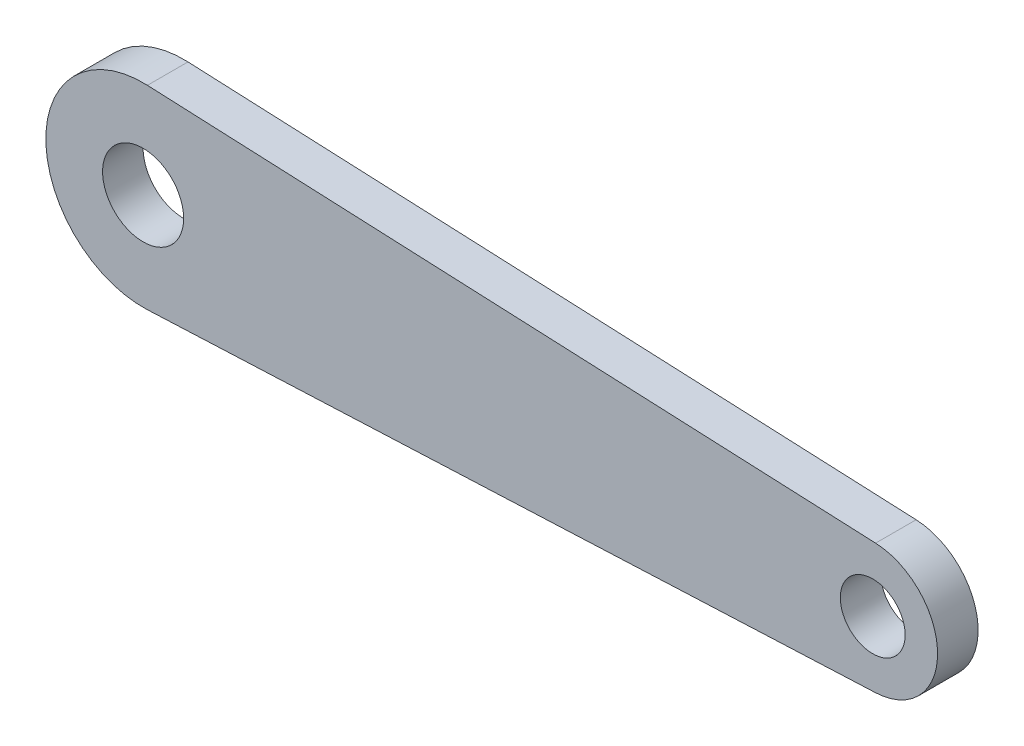
from build123d import *

# Parameters (mm, degrees)
SKETCH1_R           = 3.175
SKETCH1_R_2         = 2.54
BOSS_EXTRUDE1_DEPTH = 3.175


with BuildPart() as part:
    # Sketch1 → Boss-Extrude1 (new body)
    with BuildSketch(Plane.XY):
        with BuildLine():
            Line((0.338666667, 7.612470354), (57.375777778, 5.074980236))
            ThreePointArc((57.375777778, 5.074980236), (62.23, 0), (57.375777778, -5.074980236))
            Line((57.375777778, -5.074980236), (0.338666667, -7.612470354))
            ThreePointArc((0.338666667, -7.612470354), (-7.62, 0), (0.338666667, 7.612470354))
        make_face()
        Circle(SKETCH1_R, mode=Mode.SUBTRACT)
        with Locations((57.15, 0)):
            Circle(SKETCH1_R_2, mode=Mode.SUBTRACT)
    extrude(amount=BOSS_EXTRUDE1_DEPTH)


solid = part.part
